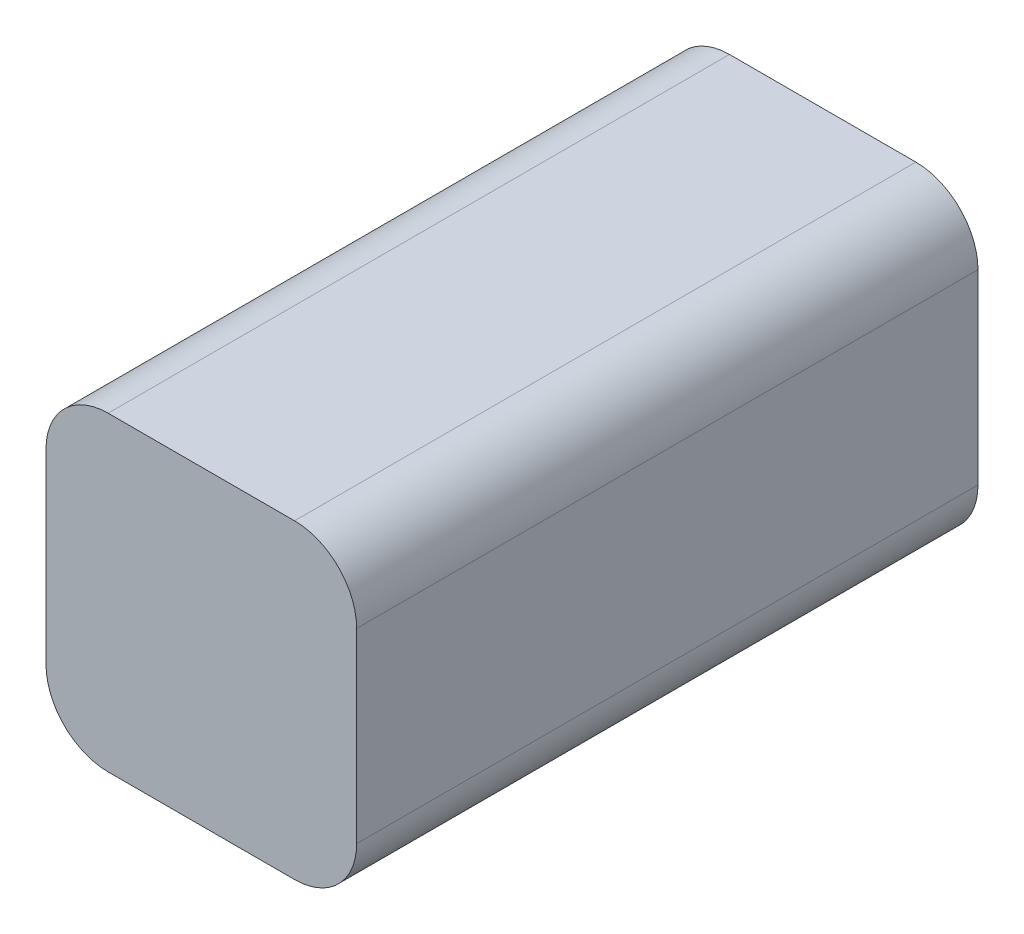
from build123d import *

# Parameters (mm, degrees)
Y_KSEKLIK_EKSTR_ZYON1_DEPTH = 50
Y_KSEKLIK_EKSTR_ZYON2_DEPTH = 7.5


with BuildPart() as part:
    # Çizim1 → Yükseklik-Ekstrüzyon1 (new body)
    with BuildSketch(Plane.XY):
        with BuildLine():
            Line((-7.5, 12.5), (7.5, 12.5))
            ThreePointArc((7.5, 12.5), (11.035533906, 11.035533906), (12.5, 7.5))
            Line((12.5, 7.5), (12.5, -7.5))
            ThreePointArc((12.5, -7.5), (11.035533906, -11.035533906), (7.5, -12.5))
            Line((7.5, -12.5), (-7.5, -12.5))
            ThreePointArc((-7.5, -12.5), (-11.035533906, -11.035533906), (-12.5, -7.5))
            Line((-12.5, -7.5), (-12.5, 7.5))
            ThreePointArc((-12.5, 7.5), (-11.035533906, 11.035533906), (-7.5, 12.5))
        make_face()
    extrude(amount=Y_KSEKLIK_EKSTR_ZYON1_DEPTH)

    # Çizim2 → Yükseklik-Ekstrüzyon2 (add)
    with BuildSketch(Plane.XY):
        with BuildLine():
            Line((1.75, 3.75), (-1.75, 3.75))
            ThreePointArc((-1.75, 3.75), (-3.164213562, 3.164213562), (-3.75, 1.75))
            Line((-3.75, 1.75), (-3.75, -1.75))
            ThreePointArc((-3.75, -1.75), (-3.164213562, -3.164213562), (-1.75, -3.75))
            Line((-1.75, -3.75), (1.75, -3.75))
            ThreePointArc((1.75, -3.75), (3.164213562, -3.164213562), (3.75, -1.75))
            Line((3.75, -1.75), (3.75, 1.75))
            ThreePointArc((3.75, 1.75), (3.164213562, 3.164213562), (1.75, 3.75))
        make_face()
    extrude(amount=-Y_KSEKLIK_EKSTR_ZYON2_DEPTH)


solid = part.part
